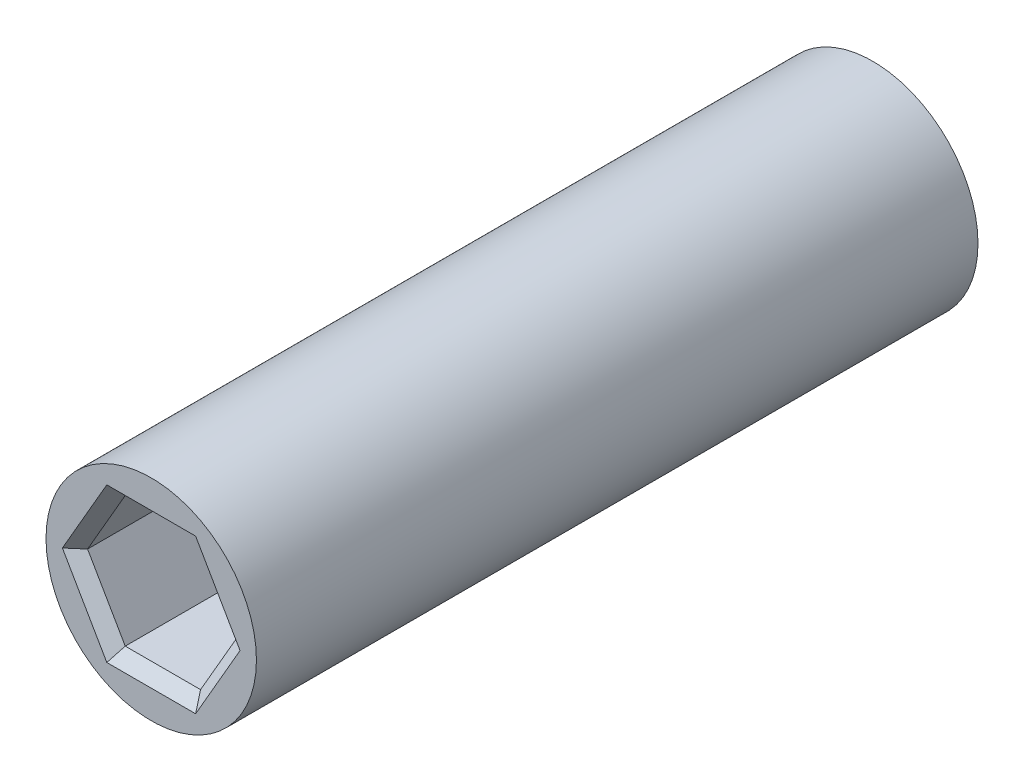
from build123d import *

# Parameters (mm, degrees)
SKETCH1_W          = 4.5
SKETCH1_H          = 30.85997733
CUT_EXTRUDE1_DEPTH = 7
CUT_EXTRUDE2_DEPTH = 7
CHAMFER1_SIZE      = 0.5
CUT_EXTRUDE3_DEPTH = 1


with BuildPart() as part:
    # Sketch1 → Revolve-Thin1 (revolve)
    with BuildSketch(Plane(origin=(0, 0, 0), x_dir=(1, 0, 0), z_dir=(0, 1, 0))):
        with Locations((2.25, 32.929988665)):
            Rectangle(SKETCH1_W, SKETCH1_H)
    revolve(axis=Axis((0, 0, 0), (0, 0, -1)))

    # Sketch2 → Cut-Extrude1 (cut)
    with BuildSketch(Plane.XY.offset(-17.5)):
        Polygon((1.610807251, 2.79), (-1.610807251, 2.79), (-3.221614502, 0), (-1.610807251, -2.79), (1.610807251, -2.79), (3.221614502, 0), align=None)
    extrude(amount=-CUT_EXTRUDE1_DEPTH, mode=Mode.SUBTRACT)

    # Sketch3 → Cut-Extrude2 (cut)
    with BuildSketch(Plane(origin=(0, 0, -48.35997733), x_dir=(-1, 0, 0), z_dir=(0, 0, -1))):
        Polygon((1.610807251, 2.79), (-1.610807251, 2.79), (-3.221614502, 0), (-1.610807251, -2.79), (1.610807251, -2.79), (3.221614502, 0), align=None)
    extrude(amount=-CUT_EXTRUDE2_DEPTH, mode=Mode.SUBTRACT)

    # Chamfer1
    chamfer1_edges = [part.edges().sort_by_distance(p)[0] for p in [
        (2.416210877, 1.395, -17.5),
        (0, 2.79, -17.5),
        (-2.416210877, 1.395, -17.5),
        (-2.416210877, -1.395, -17.5),
        (0, -2.79, -17.5),
        (2.416210877, -1.395, -17.5),
        (-2.416210877, 1.395, -48.35997733),
        (0, 2.79, -48.35997733),
        (2.416210877, 1.395, -48.35997733),
        (2.416210877, -1.395, -48.35997733),
        (0, -2.79, -48.35997733),
        (-2.416210877, -1.395, -48.35997733),
    ]]
    chamfer(chamfer1_edges, length=CHAMFER1_SIZE)

    # Sketch4 → Cut-Extrude3 (cut)
    with BuildSketch(Plane(origin=(0, -4.5, 0), x_dir=(1, 0, 0), z_dir=(0, 1, 0))):
        with BuildLine():
            Line((-0.735236378, 36.104988665), (-0.183809095, 36.104988665))
            add(Edge.make_bspline(
                [(-0.183809095, 36.104988665), (-0.142887229, 36.104821435), (-0.063984952, 36.104498996), (0.049479088, 36.099913909), (0.153619775, 36.092996425), (0.248313279, 36.083867435), (0.333638661, 36.071201473), (0.40941848, 36.055993448), (0.47613676, 36.039057193), (0.516147477, 36.02331892), (0.534890825, 36.015946197)],
                knots=[0, 0, 0, 0, 0.000122758, 0.000236692, 0.000340599, 0.000435844, 0.000522015, 0.000599225, 0.000667726, 0.000728098, 0.000728098, 0.000728098, 0.000728098], degree=3))
            add(Edge.make_bspline(
                [(0.534890825, 36.015946197), (0.555993425, 36.006429933), (0.597245667, 35.987827142), (0.656357727, 35.95629427), (0.711711569, 35.922324809), (0.762389804, 35.884637999), (0.8094619, 35.84482071), (0.852635966, 35.802494227), (0.891564361, 35.757008969), (0.926655631, 35.709180776), (0.957858636, 35.659071505), (0.984643202, 35.606434054), (1.007803352, 35.551714066), (1.025889509, 35.49431609), (1.04092128, 35.434929127), (1.050643284, 35.373178483), (1.057485172, 35.309272455), (1.058047365, 35.265888615), (1.058333333, 35.243820796)],
                knots=[0, 0, 0, 0, 6.9431e-05, 0.000135726, 0.000200852, 0.000264074, 0.000324989, 0.000385705, 0.00044524, 0.000504393, 0.000563519, 0.000622115, 0.000681412, 0.000741551, 0.000802483, 0.00086501, 0.000928929, 0.000995103, 0.000995103, 0.000995103, 0.000995103], degree=3))
            add(Edge.make_bspline(
                [(1.058333333, 35.243820796), (1.057660809, 35.216664827), (1.056333136, 35.163054546), (1.047657842, 35.083998974), (1.031477343, 35.008136947), (1.009687089, 34.93522949), (0.982690716, 34.864804536), (0.947875359, 34.798087533), (0.907633136, 34.733916018), (0.861157476, 34.67313132), (0.809209736, 34.61517584), (0.749228296, 34.563460322), (0.684531415, 34.51450675), (0.612461254, 34.471597247), (0.53499992, 34.431738139), (0.45038063, 34.397967081), (0.360191554, 34.366801607), (0.296952619, 34.351203721), (0.264583333, 34.343219835)],
                knots=[0, 0, 0, 0, 8.1472e-05, 0.00016084, 0.000238178, 0.00031384, 0.000388957, 0.000464053, 0.000539224, 0.00061593, 0.000693367, 0.000772226, 0.000853128, 0.000936463, 0.001023502, 0.00111421, 0.001209545, 0.001309511, 0.001309511, 0.001309511, 0.001309511], degree=3))
            Line((0.264583333, 34.343219835), (0.997275641, 32.929988665))
            Line((0.997275641, 32.929988665), (0.360621995, 32.929988665))
            Line((0.360621995, 32.929988665), (-0.356805889, 34.313963024))
            Line((-0.356805889, 34.313963024), (-0.41023137, 34.313963024))
            Line((-0.41023137, 34.313963024), (-0.605488782, 32.929988665))
            Line((-0.605488782, 32.929988665), (-1.180448718, 32.929988665))
            Line((-1.180448718, 32.929988665), (-0.735236378, 36.104988665))
        make_face()
        with BuildLine():
            add(Edge.make_bspline(
                [(-0.335817308, 34.843129691), (-0.294894066, 34.843508532), (-0.2166182, 34.84423316), (-0.104827079, 34.849303715), (-0.004219131, 34.857224722), (0.08509361, 34.868749131), (0.16339231, 34.882182886), (0.230523904, 34.899038904), (0.286593934, 34.919072013), (0.332485643, 34.942831056), (0.369661123, 34.970726112), (0.40183809, 35.00049459), (0.428631207, 35.033817084), (0.450737928, 35.070134204), (0.467788114, 35.109521218), (0.480083934, 35.152244969), (0.486882391, 35.198020591), (0.487927508, 35.229595041), (0.488461538, 35.245728849)],
                knots=[0, 0, 0, 0, 0.000122766, 0.000234821, 0.000335651, 0.000425427, 0.000504898, 0.000573853, 0.000632811, 0.000683169, 0.0007282, 0.000771845, 0.000814359, 0.000856026, 0.000899036, 0.000942718, 0.000989043, 0.001037447, 0.001037447, 0.001037447, 0.001037447], degree=3))
            add(Edge.make_bspline(
                [(0.488461538, 35.245728849), (0.487770257, 35.264022258), (0.486429265, 35.299508964), (0.474830234, 35.35062006), (0.454996287, 35.39698474), (0.427122393, 35.438159863), (0.392337213, 35.474465682), (0.349901429, 35.504369125), (0.300298842, 35.527903238), (0.253836196, 35.543471254), (0.210053836, 35.552396101), (0.169082237, 35.558639509), (0.120514754, 35.564294057), (0.064292994, 35.568668304), (0.000652546, 35.571550346), (-0.070576621, 35.574306307), (-0.149461846, 35.575296954), (-0.204585812, 35.575641686), (-0.23341847, 35.575821998)],
                knots=[0, 0, 0, 0, 5.483e-05, 0.000106364, 0.000156221, 0.00020526, 0.000254739, 0.000306272, 0.000360034, 0.000418964, 0.000452769, 0.000493968, 0.000543275, 0.000599421, 0.000663102, 0.000734382, 0.000813258, 0.000899759, 0.000899759, 0.000899759, 0.000899759], degree=3))
            Line((-0.23341847, 35.575821998), (-0.335817308, 34.843129691))
        make_face(mode=Mode.SUBTRACT)
    extrude(amount=CUT_EXTRUDE3_DEPTH, mode=Mode.SUBTRACT)


solid = part.part
